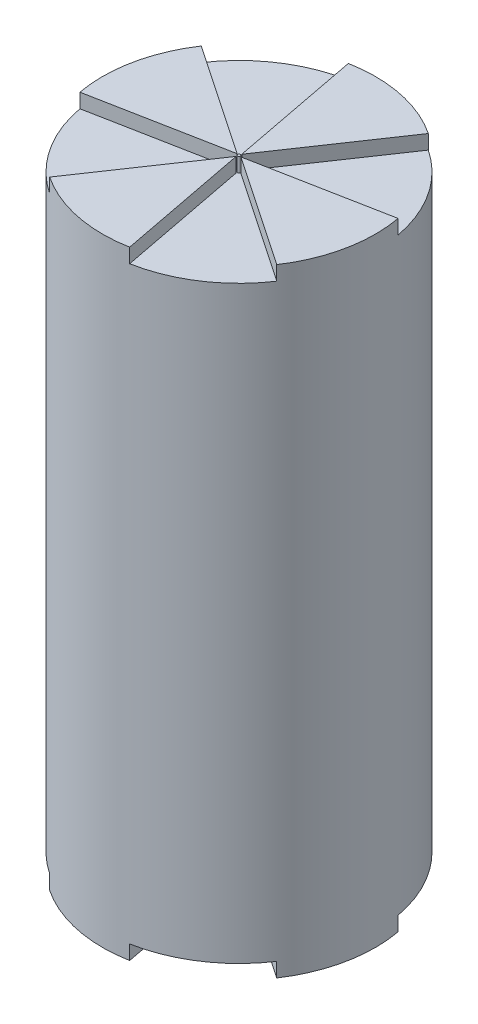
from build123d import *

# Parameters (mm, degrees)
SKETCH1_R            = 24.13
BOSS_EXTRUDE1_DEPTH  = 109.22
CUT_EXTRUDE7_DEPTH   = 2.54
CIRPATTERN2_COUNT    = 4
MIRROR1_COPY_1_DEPTH = 2.54
MIRROR1_COPY_2_DEPTH = 2.54
MIRROR1_COPY_3_DEPTH = 2.54


with BuildPart() as part:
    # Sketch1 → Boss-Extrude1 (new body)
    with BuildSketch(Plane(origin=(0, 0, 0), x_dir=(1, 0, 0), z_dir=(0, 1, 0))):
        Circle(SKETCH1_R)
    extrude(amount=BOSS_EXTRUDE1_DEPTH)

    # Sketch2 → Cut-Extrude7 (cut)
    with BuildSketch(Plane(origin=(0, 109.22, 0), x_dir=(1, 0, 0), z_dir=(0, 1, 0))):
        with BuildLine():
            Line((-13.398366618, -20.068399836), (0.023672, -0.252894516))
            ThreePointArc((0.023672, -0.252894516), (-0.212080054, -0.139778577), (-0.223069042, 0.12147511))
            Line((-0.223069042, 0.12147511), (-23.725561751, -4.399388549))
            ThreePointArc((-23.725561751, -4.399388549), (-20.147605145, -13.278964829), (-13.398366618, -20.068399836))
        make_face()
    cut_extrude7 = extrude(amount=-CUT_EXTRUDE7_DEPTH, mode=Mode.SUBTRACT)

    # CirPattern2: Cut-Extrude7 ×4 about axis
    cirpattern2_axis = Axis((0, 0, 0), (0, 1, 0))
    for i in range(1, CIRPATTERN2_COUNT):
        add(cut_extrude7.rotate(cirpattern2_axis, i * 360 / CIRPATTERN2_COUNT), mode=Mode.SUBTRACT)

    # Mirror1: Cut-Extrude7 across plane
    add(cut_extrude7.mirror(Plane.ZX.offset(54.61)), mode=Mode.SUBTRACT)

    # Mirror1 copy 1 sketch → Mirror1 copy 1 (cut)
    with BuildSketch(Plane(origin=(0, 0, 0), x_dir=(0, 0, -1), z_dir=(0, -1, 0))):
        with BuildLine():
            Line((-13.398366618, 20.068399836), (0.023672, 0.252894516))
            ThreePointArc((0.023672, 0.252894516), (-0.212080054, 0.139778577), (-0.223069042, -0.12147511))
            Line((-0.223069042, -0.12147511), (-23.725561751, 4.399388549))
            ThreePointArc((-23.725561751, 4.399388549), (-20.147605145, 13.278964829), (-13.398366618, 20.068399836))
        make_face()
    extrude(amount=-MIRROR1_COPY_1_DEPTH, mode=Mode.SUBTRACT)

    # Mirror1 copy 2 sketch → Mirror1 copy 2 (cut)
    with BuildSketch(Plane(origin=(0, 0, 0), x_dir=(-1, 0, 0), z_dir=(0, -1, 0))):
        with BuildLine():
            Line((-13.398366618, 20.068399836), (0.023672, 0.252894516))
            ThreePointArc((0.023672, 0.252894516), (-0.212080054, 0.139778577), (-0.223069042, -0.12147511))
            Line((-0.223069042, -0.12147511), (-23.725561751, 4.399388549))
            ThreePointArc((-23.725561751, 4.399388549), (-20.147605145, 13.278964829), (-13.398366618, 20.068399836))
        make_face()
    extrude(amount=-MIRROR1_COPY_2_DEPTH, mode=Mode.SUBTRACT)

    # Mirror1 copy 3 sketch → Mirror1 copy 3 (cut)
    with BuildSketch(Plane(origin=(0, 0, 0), x_dir=(0, 0, 1), z_dir=(0, -1, 0))):
        with BuildLine():
            Line((-13.398366618, 20.068399836), (0.023672, 0.252894516))
            ThreePointArc((0.023672, 0.252894516), (-0.212080054, 0.139778577), (-0.223069042, -0.12147511))
            Line((-0.223069042, -0.12147511), (-23.725561751, 4.399388549))
            ThreePointArc((-23.725561751, 4.399388549), (-20.147605145, 13.278964829), (-13.398366618, 20.068399836))
        make_face()
    extrude(amount=-MIRROR1_COPY_3_DEPTH, mode=Mode.SUBTRACT)


solid = part.part
